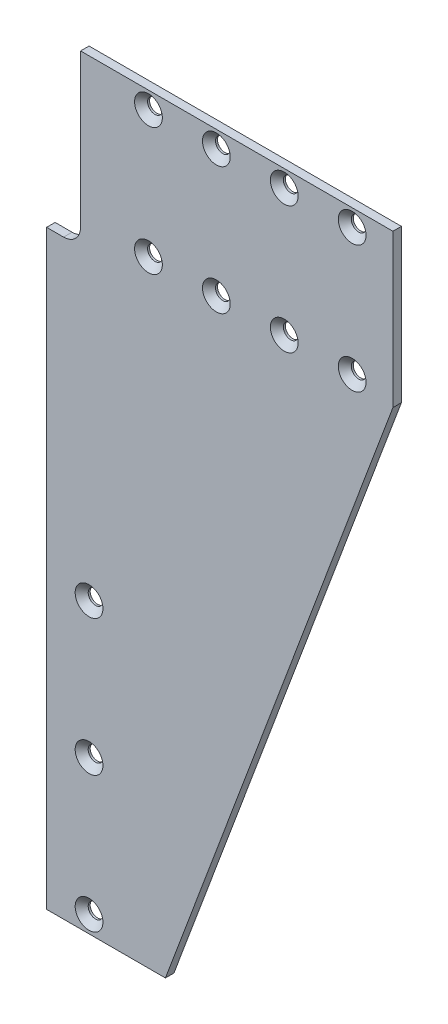
from build123d import *

# Parameters (mm, degrees)
BOSS_EXTRUDE1_DEPTH                       = 3.175
CSK_FOR_0_FLAT_HEAD_MACHINE_SCREW_2_COUNT = 2
CSK_FOR_0_FLAT_HEAD_MACHINE_SCREW_2_PITCH = 47.625
LPATTERN1_COUNT                           = 4
LPATTERN1_PITCH                           = 25.4
LPATTERN2_COUNT                           = 3
LPATTERN2_PITCH                           = 50.8


with BuildPart() as part:
    # Sketch1 → Boss-Extrude1 (new body)
    with BuildSketch(Plane.XY):
        with BuildLine():
            Line((0, 0), (0, 220.98))
            Line((0, 220.98), (6.35, 220.98))
            ThreePointArc((6.35, 220.98), (10.840128061, 222.839871939), (12.7, 227.33))
            Line((12.7, 227.33), (12.7, 284.48))
            Line((12.7, 284.48), (129.54, 284.48))
            Line((129.54, 284.48), (129.54, 227.33))
            Line((129.54, 227.33), (44.45, 0))
            Line((44.45, 0), (0, 0))
        make_face()
    extrude(amount=-BOSS_EXTRUDE1_DEPTH)

    # Sketch3 → CSK for _0 Flat Head Machine Screw _100 (revolve, cut)
    with BuildSketch(Plane(origin=(38.1, 278.13, 0), x_dir=(0, -1, 0), z_dir=(1, 0, 0))):
        Polygon((0, 0), (0, 3.175), (2.7559, 3.175), (2.7559, 2.4384), (5.1943, 0), align=None)
    csk_for_0_flat_head_machine_screw_100 = revolve(axis=Axis((38.1, 278.13, 6.35), (0, 0, -1)), mode=Mode.SUBTRACT)

    # CSK for _0 Flat Head Machine Screw _ 2: CSK for _0 Flat Head Machine Screw _100 ×2
    with Locations(*[(0, -i * CSK_FOR_0_FLAT_HEAD_MACHINE_SCREW_2_PITCH, 0) for i in range(1, CSK_FOR_0_FLAT_HEAD_MACHINE_SCREW_2_COUNT)]):
        add(csk_for_0_flat_head_machine_screw_100, mode=Mode.SUBTRACT)

    # LPattern1: CSK for _0 Flat Head Machine Screw _100 ×4
    with Locations(*[(i * LPATTERN1_PITCH, 0, 0) for i in range(1, LPATTERN1_COUNT)]):
        add(csk_for_0_flat_head_machine_screw_100, mode=Mode.SUBTRACT)

    # LPattern1 copy 1 sketch → LPattern1 copy 1 (revolve, cut)
    with BuildSketch(Plane(origin=(63.5, 230.505, 0), x_dir=(0, -1, 0), z_dir=(1, 0, 0))):
        Polygon((0, 0), (0, 3.175), (2.7559, 3.175), (2.7559, 2.4384), (5.1943, 0), align=None)
    revolve(axis=Axis((63.5, 230.505, 6.35), (0, 0, -1)), mode=Mode.SUBTRACT)

    # LPattern1 copy 2 sketch → LPattern1 copy 2 (revolve, cut)
    with BuildSketch(Plane(origin=(88.9, 230.505, 0), x_dir=(0, -1, 0), z_dir=(1, 0, 0))):
        Polygon((0, 0), (0, 3.175), (2.7559, 3.175), (2.7559, 2.4384), (5.1943, 0), align=None)
    revolve(axis=Axis((88.9, 230.505, 6.35), (0, 0, -1)), mode=Mode.SUBTRACT)

    # LPattern1 copy 3 sketch → LPattern1 copy 3 (revolve, cut)
    with BuildSketch(Plane(origin=(114.3, 230.505, 0), x_dir=(0, -1, 0), z_dir=(1, 0, 0))):
        Polygon((0, 0), (0, 3.175), (2.7559, 3.175), (2.7559, 2.4384), (5.1943, 0), align=None)
    revolve(axis=Axis((114.3, 230.505, 6.35), (0, 0, -1)), mode=Mode.SUBTRACT)

    # Sketch4 → CSK for _0 Flat Head Machine Screw _ 3 (revolve, cut)
    with BuildSketch(Plane(origin=(15.875, 107.95, 0), x_dir=(0, -1, 0), z_dir=(1, 0, 0))):
        Polygon((0, 0), (0, 3.175), (2.7559, 3.175), (2.7559, 2.4384), (5.1943, 0), align=None)
    csk_for_0_flat_head_machine_screw_3 = revolve(axis=Axis((15.875, 107.95, 6.35), (0, 0, -1)), mode=Mode.SUBTRACT)

    # LPattern2: CSK for _0 Flat Head Machine Screw _ 3 ×3
    with Locations(*[(0, -i * LPATTERN2_PITCH, 0) for i in range(1, LPATTERN2_COUNT)]):
        add(csk_for_0_flat_head_machine_screw_3, mode=Mode.SUBTRACT)


solid = part.part
